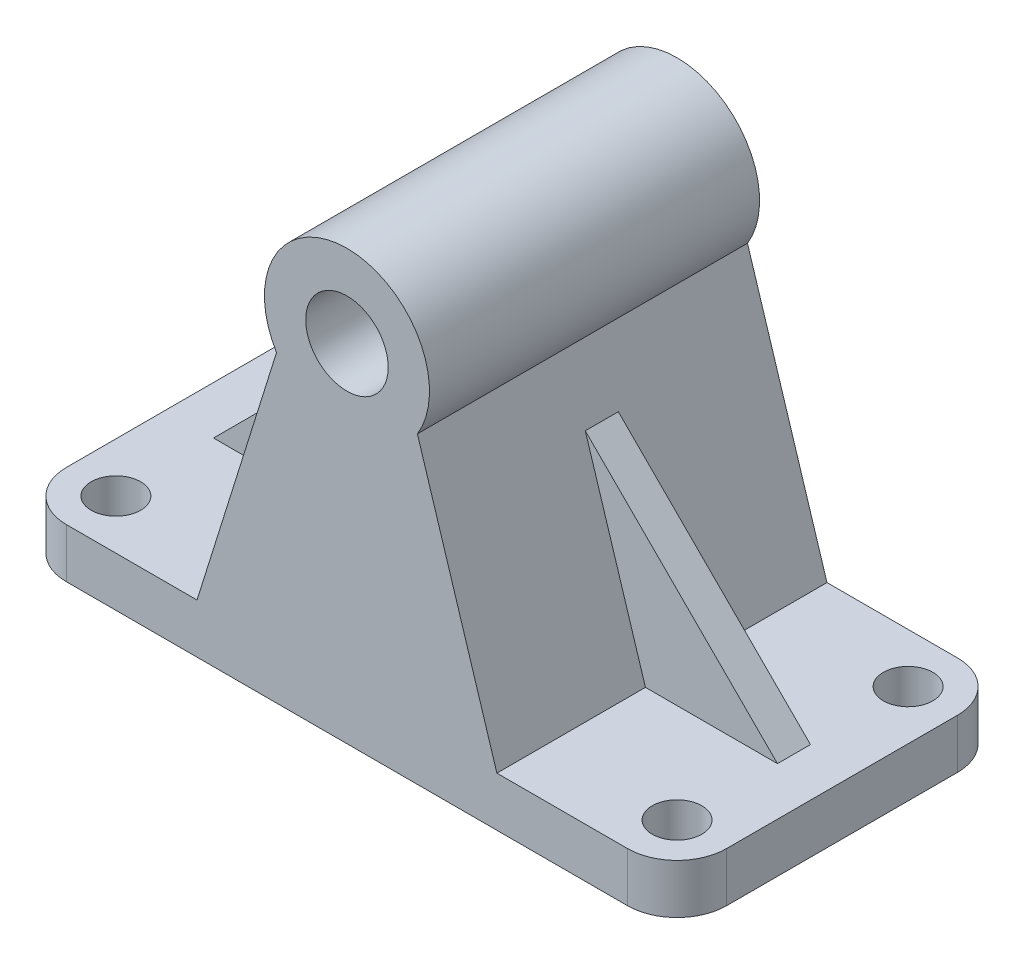
from build123d import *

# Parameters (mm, degrees)
BOSS_EXTRUDE1_DEPTH = 15
SKETCH2_R           = 7.5
CUT_EXTRUDE1_DEPTH  = 15
BOSS_EXTRUDE2_DEPTH = 50
SKETCH4_R           = 12.5
CUT_EXTRUDE2_DEPTH  = 50
BOSS_EXTRUDE3_DEPTH = 5


with BuildPart() as part:
    # Sketch1 → Boss-Extrude1 (new body)
    with BuildSketch(Plane(origin=(0, 0, 0), x_dir=(1, 0, 0), z_dir=(0, 1, 0))):
        with BuildLine():
            Line((85, -50), (-85, -50))
            ThreePointArc((-85, -50), (-95.606601718, -45.606601718), (-100, -35))
            Line((-100, -35), (-100, 35))
            ThreePointArc((-100, 35), (-95.606601718, 45.606601718), (-85, 50))
            Line((-85, 50), (85, 50))
            ThreePointArc((85, 50), (95.606601718, 45.606601718), (100, 35))
            Line((100, 35), (100, -35))
            ThreePointArc((100, -35), (95.606601718, -45.606601718), (85, -50))
        make_face()
    extrude(amount=BOSS_EXTRUDE1_DEPTH)

    # Sketch2 → Cut-Extrude1 (cut)
    with BuildSketch(Plane(origin=(0, 15, 0), x_dir=(1, 0, 0), z_dir=(0, 1, 0))):
        with Locations((-85, 35)):
            Circle(SKETCH2_R)
        with Locations((-85, -35)):
            Circle(SKETCH2_R)
        with Locations((85, -35)):
            Circle(SKETCH2_R)
        with Locations((85, 35)):
            Circle(SKETCH2_R)
    extrude(amount=-CUT_EXTRUDE1_DEPTH, mode=Mode.SUBTRACT)

    # Sketch3 → Boss-Extrude2 (add, symmetric)
    with BuildSketch(Plane.XY):
        with BuildLine():
            Line((-45.424155313, 15), (-21.336304632, 91.970721254))
            ThreePointArc((-21.336304632, 91.970721254), (0, 130), (21.336304632, 91.970721254))
            Line((21.336304632, 91.970721254), (45.424155313, 15))
            Line((45.424155313, 15), (-45.424155313, 15))
        make_face()
    extrude(amount=BOSS_EXTRUDE2_DEPTH, both=True)

    # Sketch4 → Cut-Extrude2 (cut, symmetric)
    with BuildSketch(Plane.XY):
        with Locations((0, 105)):
            Circle(SKETCH4_R)
    extrude(amount=CUT_EXTRUDE2_DEPTH, both=True, mode=Mode.SUBTRACT)

    # Sketch6 → Boss-Extrude3 (add, symmetric)
    with BuildSketch(Plane.XY):
        Polygon((-85.424155313, 15), (-27.204379859, 73.219775454), (-45.424155313, 15), align=None)
        Polygon((45.424155313, 15), (27.204379859, 73.219775454), (85.424155313, 15), align=None)
    extrude(amount=BOSS_EXTRUDE3_DEPTH, both=True)


solid = part.part
